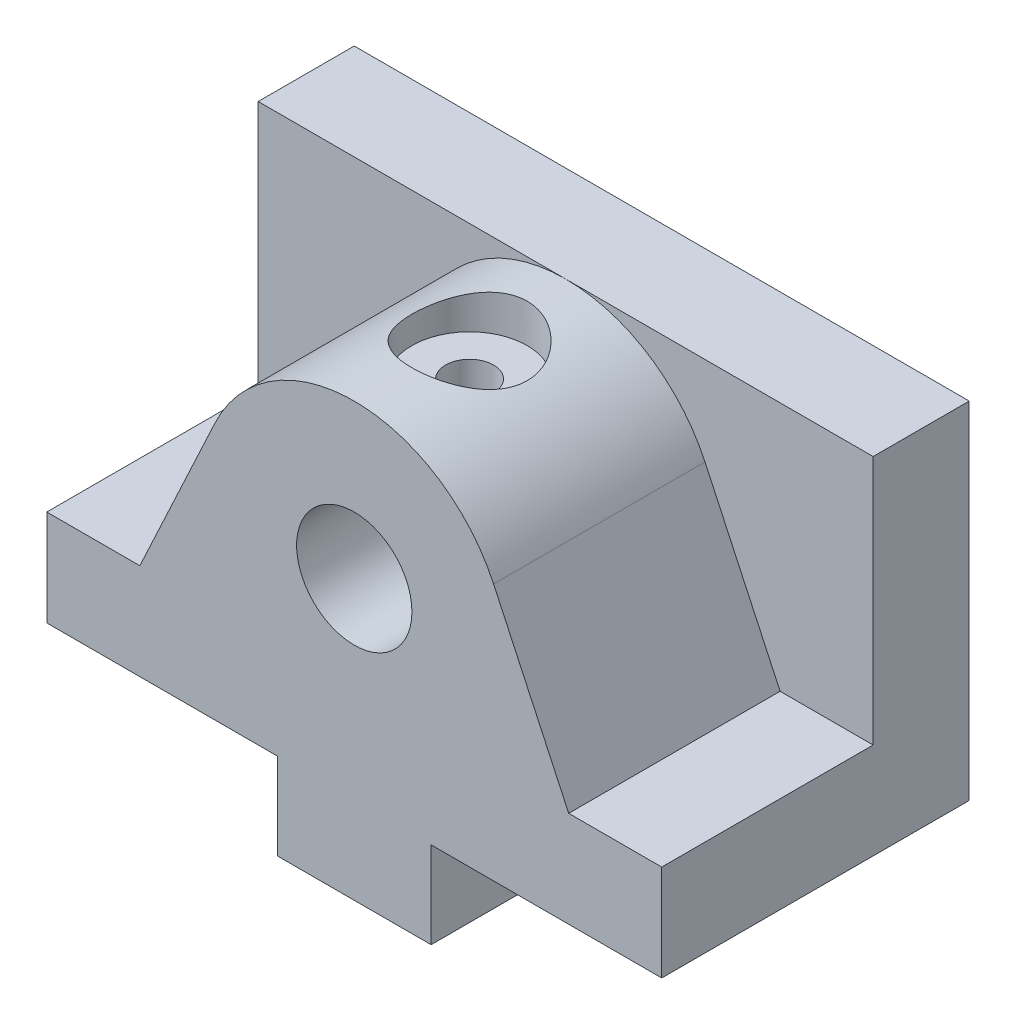
from build123d import *

# Parameters (mm, degrees)
BOSS_EXTRUDE1_DEPTH                   = 10
BOSS_EXTRUDE2_DEPTH                   = 22
F_12_0MM_DOWEL_HOLE1_D                = 12
F_12_0MM_DOWEL_HOLE1_DEPTH            = 20.394836286
F_12_0MM_DOWEL_HOLE1_TIP              = 3.605163714
TAP_DRILL_FOR_M6X1_0_TAP1_D           = 5
TAP_DRILL_FOR_M6X1_0_TAP1_DEPTH       = 16
TAP_DRILL_FOR_M6X1_0_TAP1_TIP         = 1.502151548
TAP_DRILL_FOR_M6X1_0_TAP3_D           = 5
TAP_DRILL_FOR_M6X1_0_TAP3_DEPTH       = 16
TAP_DRILL_FOR_M6X1_0_TAP3_CSINK_D     = 5.05
TAP_DRILL_FOR_M6X1_0_TAP3_CSINK_ANGLE = 100
TAP_DRILL_FOR_M6X1_0_TAP3_TIP         = 1.502151548
SKETCH13_R                            = 6
CUT_EXTRUDE1_DEPTH                    = 4


with BuildPart() as part:
    # Sketch1 → Boss-Extrude1 (new body)
    with BuildSketch(Plane.XY):
        Polygon((-32, 9), (-8, 9), (-8, 0), (8, 0), (8, 9), (32, 9), (32, 45), (-32, 45), align=None)
    extrude(amount=BOSS_EXTRUDE1_DEPTH)

    # Sketch3 → Boss-Extrude2 (add)
    with BuildSketch(Plane.XY.offset(10)):
        with BuildLine():
            Line((-32, 19), (-32, 9))
            Line((-32, 9), (-8, 9))
            Line((-8, 9), (-8, 0))
            Line((-8, 0), (8, 0))
            Line((8, 0), (8, 9))
            Line((8, 9), (32, 9))
            Line((32, 9), (32, 19))
            Line((32, 19), (22.317123285, 19))
            Line((22.317123285, 19), (14.500924593, 35.761892188))
            ThreePointArc((14.500924593, 35.761892188), (8.596793696, 42.494263157), (-8.8e-08, 45))
            ThreePointArc((-8.8e-08, 45), (-8.596793771, 42.494263109), (-14.500924593, 35.761892188))
            Line((-14.500924593, 35.761892188), (-22.317123285, 19))
            Line((-22.317123285, 19), (-32, 19))
        make_face()
    extrude(amount=BOSS_EXTRUDE2_DEPTH)

    # Ø12.0mm Dowel Hole1
    with Locations(Plane.XY.offset(32)):
        with Locations((0, 29)):
            Hole(F_12_0MM_DOWEL_HOLE1_D / 2, depth=F_12_0MM_DOWEL_HOLE1_DEPTH)
            with Locations((0, 0, -(F_12_0MM_DOWEL_HOLE1_DEPTH + F_12_0MM_DOWEL_HOLE1_TIP / 2))):  # 118° drill point
                Cone(0, F_12_0MM_DOWEL_HOLE1_D / 2, F_12_0MM_DOWEL_HOLE1_TIP, mode=Mode.SUBTRACT)

    # Tap Drill for M6x1.0 Tap1
    with Locations(Plane(origin=(0, 0, 0), x_dir=(-1, 0, 0), z_dir=(0, -1, 0))):
        with Locations((0, -8), (0, -24)):
            Hole(TAP_DRILL_FOR_M6X1_0_TAP1_D / 2, depth=TAP_DRILL_FOR_M6X1_0_TAP1_DEPTH)
            with Locations((0, 0, -(TAP_DRILL_FOR_M6X1_0_TAP1_DEPTH + TAP_DRILL_FOR_M6X1_0_TAP1_TIP / 2))):  # 118° drill point
                Cone(0, TAP_DRILL_FOR_M6X1_0_TAP1_D / 2, TAP_DRILL_FOR_M6X1_0_TAP1_TIP, mode=Mode.SUBTRACT)

    # Tap Drill for M6x1.0 Tap3
    with Locations(Plane(origin=(0, 45, 20), x_dir=(1, 0, 0), z_dir=(0, 1, 0))):
        with Locations((0, 0)):
            CounterSinkHole(TAP_DRILL_FOR_M6X1_0_TAP3_D / 2, TAP_DRILL_FOR_M6X1_0_TAP3_CSINK_D / 2, depth=TAP_DRILL_FOR_M6X1_0_TAP3_DEPTH, counter_sink_angle=TAP_DRILL_FOR_M6X1_0_TAP3_CSINK_ANGLE)
            with Locations((0, 0, -(TAP_DRILL_FOR_M6X1_0_TAP3_DEPTH + TAP_DRILL_FOR_M6X1_0_TAP3_TIP / 2))):  # 118° drill point
                Cone(0, TAP_DRILL_FOR_M6X1_0_TAP3_D / 2, TAP_DRILL_FOR_M6X1_0_TAP3_TIP, mode=Mode.SUBTRACT)

    # Sketch13 → Cut-Extrude1 (cut)
    with BuildSketch(Plane(origin=(0, 45, 0), x_dir=(1, 0, 0), z_dir=(0, 1, 0))):
        with Locations((0, -20)):
            Circle(SKETCH13_R)
    extrude(amount=-CUT_EXTRUDE1_DEPTH, mode=Mode.SUBTRACT)


solid = part.part
